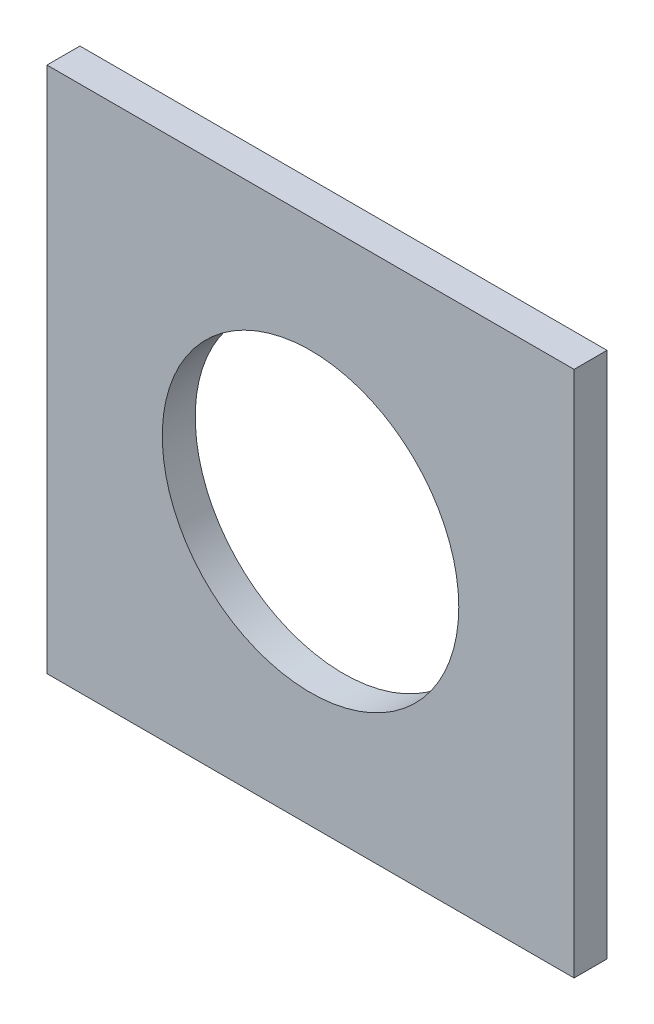
from build123d import *

# Parameters (mm, degrees)
SKETCH1_W           = 50.8
SKETCH1_H           = 50.8
BOSS_EXTRUDE1_DEPTH = 3.175
CUT_EXTRUDE1_DEPTH  = 3.175


with BuildPart() as part:
    # Sketch1 → Boss-Extrude1 (new body)
    with BuildSketch(Plane.XY):
        with Locations((4.943113772, -8.289221557)):
            Rectangle(SKETCH1_W, SKETCH1_H)
    extrude(amount=BOSS_EXTRUDE1_DEPTH)

    # Sketch2 → Cut-Extrude1 (cut)
    with BuildSketch(Plane.XY.offset(3.175)):
        with BuildLine():
            ThreePointArc((19.230613772, -8.289221557), (15.045901909, 1.813566579), (4.943113772, 5.998278443))
            Line((4.943113772, 5.998278443), (4.943113772, -8.289221557))
            Line((4.943113772, -8.289221557), (19.230613772, -8.289221557))
        make_face()
        with BuildLine():
            Line((4.943113772, -8.289221557), (4.943113772, 5.998278443))
            ThreePointArc((4.943113772, 5.998278443), (-5.159674364, 1.813566579), (-9.344386228, -8.289221557))
            Line((-9.344386228, -8.289221557), (4.943113772, -8.289221557))
        make_face()
        with BuildLine():
            Line((19.230613772, -8.289221557), (4.943113772, -8.289221557))
            Line((4.943113772, -8.289221557), (4.943113772, -22.576721557))
            ThreePointArc((4.943113772, -22.576721557), (15.045901909, -18.392009693), (19.230613772, -8.289221557))
        make_face()
        with BuildLine():
            Line((4.943113772, -22.576721557), (4.943113772, -8.289221557))
            Line((4.943113772, -8.289221557), (-9.344386228, -8.289221557))
            ThreePointArc((-9.344386228, -8.289221557), (-5.159674364, -18.392009693), (4.943113772, -22.576721557))
        make_face()
    extrude(amount=-CUT_EXTRUDE1_DEPTH, mode=Mode.SUBTRACT)


solid = part.part
